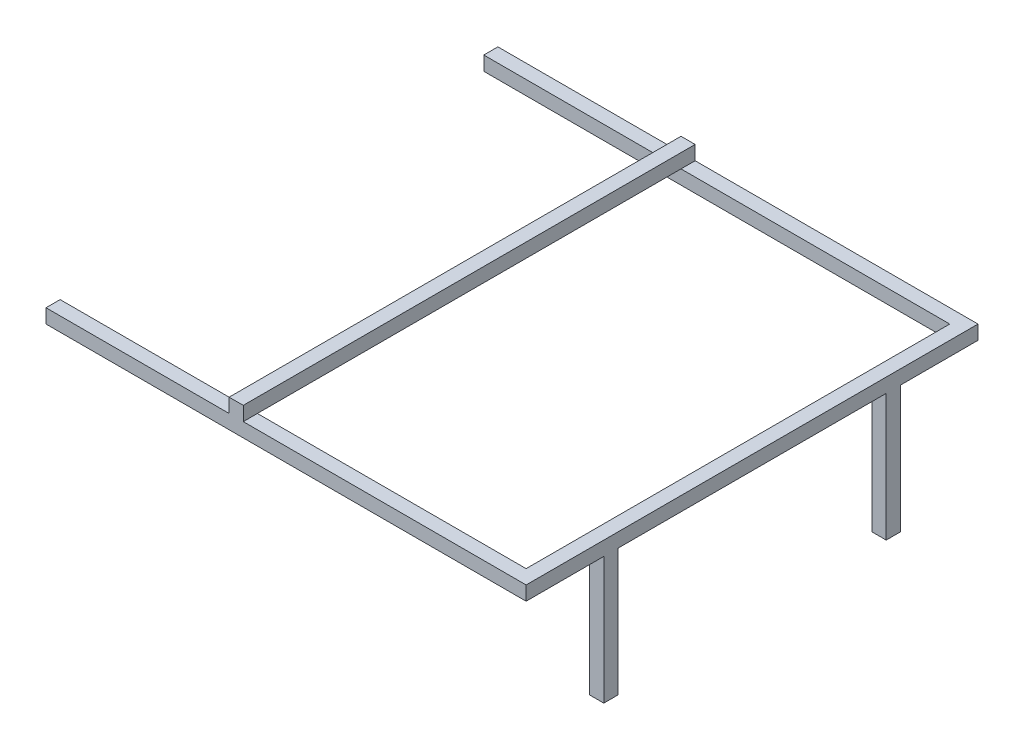
from build123d import *

# Parameters (mm, degrees)
SKETCH_1_W          = 380.612698372
SKETCH_1_H          = 600
EXTRUDE_1_DEPTH     = 20
SKETCH1_W           = 20
SKETCH1_H           = 640
BOSS_EXTRUDE1_DEPTH = 20
SKETCH2_W           = 20
SKETCH2_H           = 600
CUT_EXTRUDE1_DEPTH  = 20
SKETCH3_W           = 20
SKETCH3_H           = 20
BOSS_EXTRUDE2_DEPTH = 180


with BuildPart() as part:
    # 草图1 → 凸台-拉伸1 (new body)
    with BuildSketch(Plane(origin=(0, 0, 0), x_dir=(1, 0, 0), z_dir=(0, 1, 0))):
        Polygon((-329.38787024, -472.094950635), (-329.38787024, -492.094950635), (350.61212976, -492.094950635), (350.61212976, 147.905049365), (-329.38787024, 147.905049365), (-329.38787024, 127.905049365), (-70.000568612, 127.905049365), (-70.000568612, -472.094950635), align=None)
        with Locations((140.305780574, -172.094950635)):
            Rectangle(SKETCH_1_W, SKETCH_1_H, mode=Mode.SUBTRACT)
    extrude(amount=EXTRUDE_1_DEPTH)

    # Sketch1 → Boss-Extrude1 (add)
    with BuildSketch(Plane(origin=(0, 20, 0), x_dir=(1, 0, 0), z_dir=(0, 1, 0))):
        with Locations((-60.000568612, -172.094950635)):
            Rectangle(SKETCH1_W, SKETCH1_H)
    extrude(amount=BOSS_EXTRUDE1_DEPTH)

    # Sketch2 → Cut-Extrude1 (cut)
    with BuildSketch(Plane.XZ):
        with Locations((-60.000568612, 172.094950635)):
            Rectangle(SKETCH2_W, SKETCH2_H)
    extrude(amount=-CUT_EXTRUDE1_DEPTH, mode=Mode.SUBTRACT)

    # Sketch3 → Boss-Extrude2 (add)
    with BuildSketch(Plane.XZ):
        with Locations((340.61212976, 372.094950635)):
            Rectangle(SKETCH3_W, SKETCH3_H)
        with Locations((340.61212976, -27.905049365)):
            Rectangle(SKETCH3_W, SKETCH3_H)
    extrude(amount=BOSS_EXTRUDE2_DEPTH)


solid = part.part
